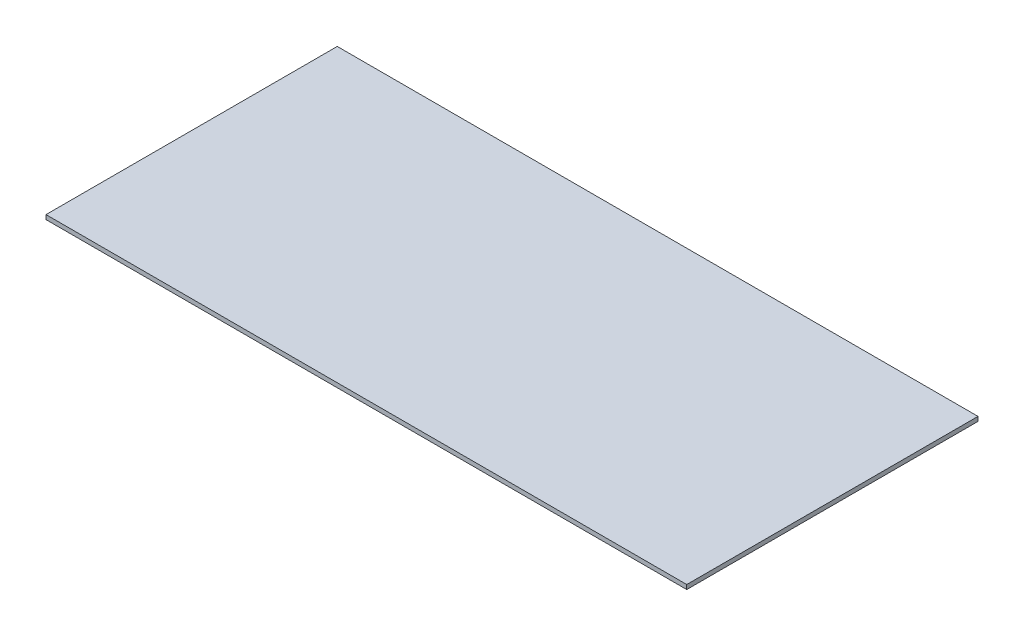
from build123d import *

# Parameters (mm, degrees)
ESBO_O2_W                = 440
ESBO_O2_H                = 200
RESSALTO_EXTRUS_O3_DEPTH = 3
ESBO_O3_W                = 50
ESBO_O3_H                = 70
RESSALTO_EXTRUS_O4_DEPTH = 15


with BuildPart() as part:
    # Esboço2 → Ressalto-extrusão3 (new body)
    with BuildSketch(Plane(origin=(0, 0, 0), x_dir=(1, 0, 0), z_dir=(0, 1, 0))):
        with Locations((236.080237004, -55.555555556)):
            Rectangle(ESBO_O2_W, ESBO_O2_H)
    extrude(amount=RESSALTO_EXTRUS_O3_DEPTH)

    # Esboço3 → Ressalto-extrusão4 (add)
    with BuildSketch(Plane(origin=(0, 0, 0), x_dir=(1, 0, 0), z_dir=(0, 1, 0))):
        with Locations((59.080237004, -56.555555556)):
            Rectangle(ESBO_O3_W, ESBO_O3_H)
    extrude(amount=-RESSALTO_EXTRUS_O4_DEPTH)


solid = part.part
